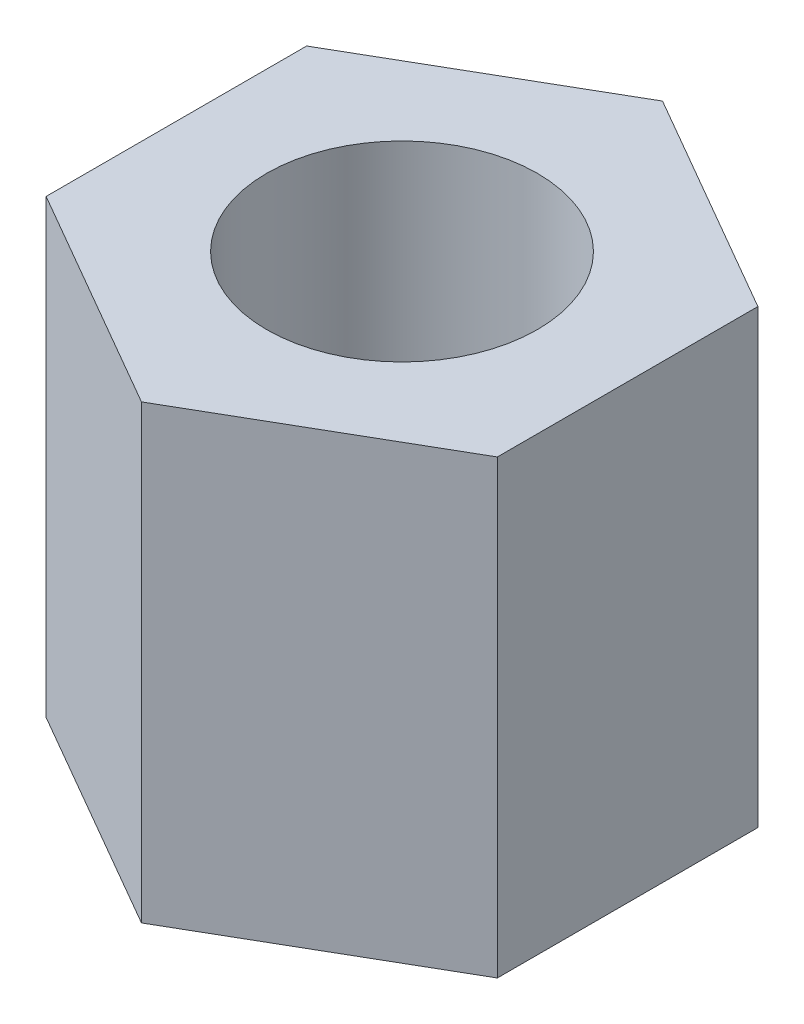
from build123d import *

# Parameters (mm, degrees)
SKETCH_1_R      = 1.5
EXTRUDE_1_DEPTH = 5


with BuildPart() as part:
    # 草圖1 → 填料-伸長1 (new body)
    with BuildSketch(Plane(origin=(0, 0, 0), x_dir=(1, 0, 0), z_dir=(0, 1, 0))):
        Polygon((0, 2.886751346), (-2.5, 1.443375673), (-2.5, -1.443375673), (0, -2.886751346), (2.5, -1.443375673), (2.5, 1.443375673), align=None)
        Circle(SKETCH_1_R, mode=Mode.SUBTRACT)
    extrude(amount=EXTRUDE_1_DEPTH)


solid = part.part
